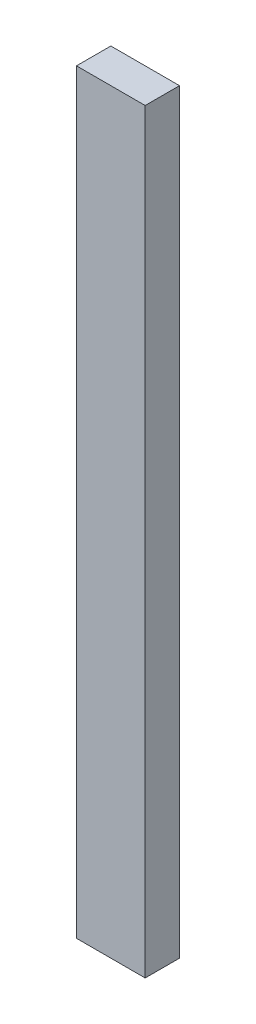
from build123d import *

# Parameters (mm, degrees)
SKETCH1_W           = 20
SKETCH1_H           = 220
BOSS_EXTRUDE1_DEPTH = 10


with BuildPart() as part:
    # Sketch1 → Boss-Extrude1 (new body)
    with BuildSketch(Plane.XY):
        with Locations((10, 110)):
            Rectangle(SKETCH1_W, SKETCH1_H)
    extrude(amount=BOSS_EXTRUDE1_DEPTH)


solid = part.part
